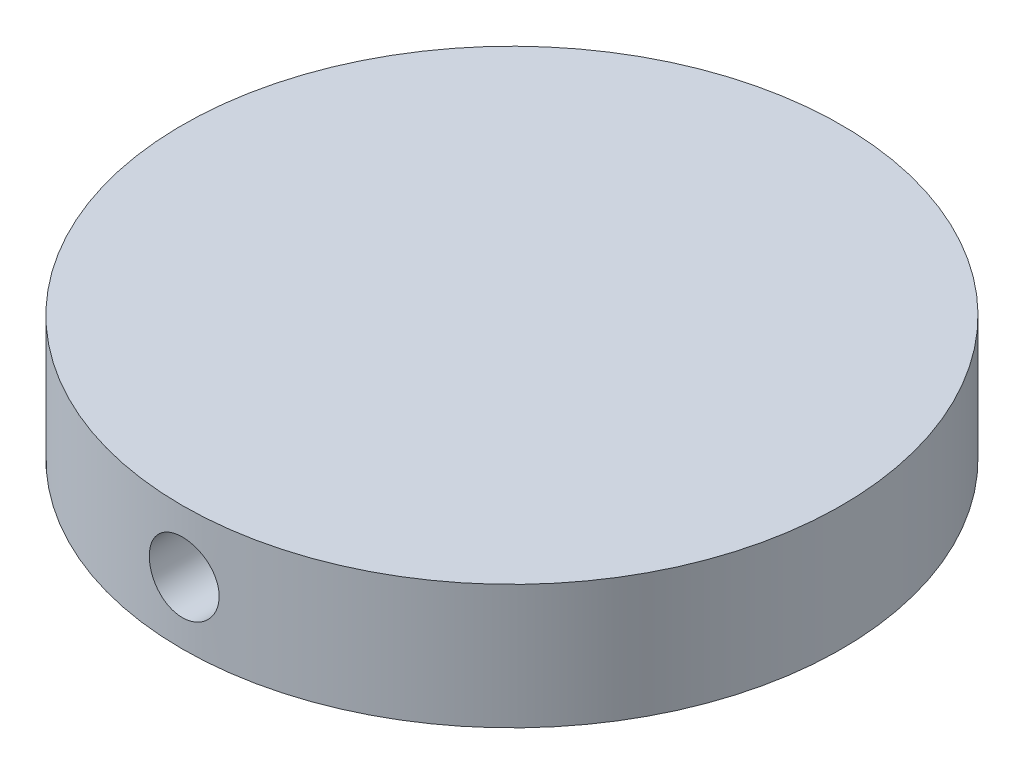
from build123d import *

# Parameters (mm, degrees)
SKETCH2_R               = 26.942694389
BOSS_EXTRUDE1_DEPTH     = 10.16
SKETCH3_R               = 2.854846783
CUT_EXTRUDE1_DEPTH      = 27.942694389
CUT_EXTRUDE1_DEPTH_BACK = 27.942694389


with BuildPart() as part:
    # Sketch2 → Boss-Extrude1 (new body)
    with BuildSketch(Plane(origin=(0, 0, 0), x_dir=(1, 0, 0), z_dir=(0, 1, 0))):
        Circle(SKETCH2_R)
    extrude(amount=BOSS_EXTRUDE1_DEPTH)

    # Sketch3 → Cut-Extrude1 (cut, two sides)
    with BuildSketch(Plane.XY) as cut_extrude1_sk:
        with Locations((0, 5.08)):
            Circle(SKETCH3_R)
    extrude(amount=CUT_EXTRUDE1_DEPTH, mode=Mode.SUBTRACT)
    extrude(cut_extrude1_sk.sketch, amount=-CUT_EXTRUDE1_DEPTH_BACK, mode=Mode.SUBTRACT)


solid = part.part
